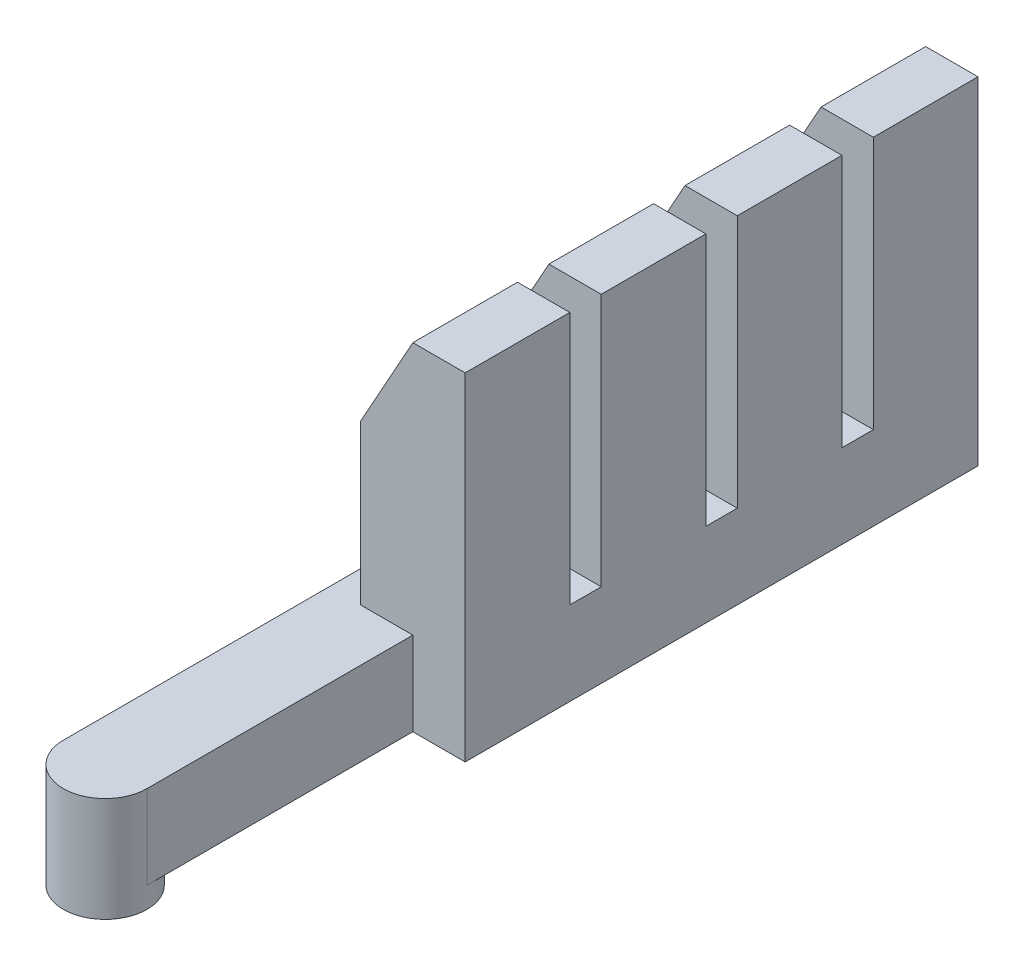
from build123d import *

# Parameters (mm, degrees)
SKETCH2_R               = 20
SKETCH2_R_2             = 10
BOSS_EXTRUDE1_DEPTH     = 80
SKETCH3_R               = 20
BOSS_EXTRUDE2_DEPTH     = 5
SKETCH4_W               = 30
SKETCH4_H               = 30
CUT_EXTRUDE1_DEPTH      = 50
SKETCH4_4_W             = 40
SKETCH4_4_H             = 40
SKETCH4_4_W_2           = 30
SKETCH4_4_H_2           = 30
BOSS_EXTRUDE3_DEPTH     = 127
SKETCH4_5_W             = 30
SKETCH4_5_H             = 30
CUT_EXTRUDE2_DEPTH      = 10
SKETCH5_R               = 10
CUT_EXTRUDE3_DEPTH      = 50
BOSS_EXTRUDE4_DEPTH     = 245
SKETCH7_W               = 25
SKETCH7_H               = 5
SKETCH7_W_2             = 55.000380238
BOSS_EXTRUDE5_DEPTH     = 35
SKETCH11_W              = 65
SKETCH11_H              = 5
BOSS_EXTRUDE9_DEPTH     = 245
SKETCH9_W               = 40
SKETCH9_H               = 40
CUT_EXTRUDE4_DEPTH      = 10
SKETCH9_4_W             = 50
SKETCH9_4_H             = 50
SKETCH9_4_W_2           = 40
SKETCH9_4_H_2           = 40
BOSS_EXTRUDE10_DEPTH    = 116
SKETCH13_W              = 50
SKETCH13_H              = 50
BOSS_EXTRUDE11_DEPTH    = 5
SKETCH14_W              = 40
SKETCH14_H              = 40
CUT_EXTRUDE5_DEPTH      = 5
CUT_EXTRUDE6_DEPTH      = 446.112345369
CUT_EXTRUDE7_DEPTH      = 431.168571609
CUT_EXTRUDE7_DEPTH_BACK = 431.168571609
SKETCH16_W              = 40
SKETCH16_H              = 35


with BuildPart() as part:
    # Sketch2 → Boss-Extrude1 (new body)
    with BuildSketch(Plane(origin=(0, 0, 0), x_dir=(1, 0, 0), z_dir=(0, 1, 0))):
        Circle(SKETCH2_R)
        Circle(SKETCH2_R_2, mode=Mode.SUBTRACT)
    extrude(amount=BOSS_EXTRUDE1_DEPTH)

    # Sketch3 → Boss-Extrude2 (add)
    with BuildSketch(Plane(origin=(0, 80, 0), x_dir=(1, 0, 0), z_dir=(0, 1, 0))):
        Circle(SKETCH3_R)
    extrude(amount=BOSS_EXTRUDE2_DEPTH)

    # Sketch4 → Cut-Extrude1 (cut)
    with BuildSketch(Plane.XY):
        with Locations((0, 65)):
            Rectangle(SKETCH4_W, SKETCH4_H)
    extrude(amount=-CUT_EXTRUDE1_DEPTH, mode=Mode.SUBTRACT)

    # Sketch4_4 → Boss-Extrude3 (add)
    with BuildSketch(Plane.XY):
        with Locations((0, 65)):
            Rectangle(SKETCH4_4_W, SKETCH4_4_H)
        with Locations((0, 65)):
            Rectangle(SKETCH4_4_W_2, SKETCH4_4_H_2, mode=Mode.SUBTRACT)
    extrude(amount=-BOSS_EXTRUDE3_DEPTH)

    # Sketch4_5 → Cut-Extrude2 (cut)
    with BuildSketch(Plane.XY):
        with Locations((0, 65)):
            Rectangle(SKETCH4_5_W, SKETCH4_5_H)
    extrude(amount=CUT_EXTRUDE2_DEPTH, mode=Mode.SUBTRACT)

    # Sketch5 → Cut-Extrude3 (cut)
    with BuildSketch(Plane.XZ):
        Circle(SKETCH5_R)
    extrude(amount=-CUT_EXTRUDE3_DEPTH, mode=Mode.SUBTRACT)

    # Sketch6 → Boss-Extrude4 (add)
    with BuildSketch(Plane(origin=(0, 0, -127), x_dir=(-1, 0, 0), z_dir=(0, 0, -1))):
        Polygon((0, 80), (0, 85), (20, 85), (20, 45), (-45, 45), (-45, 85), (-40, 85), (-40, 49.795485049), (15, 50), (15, 80), align=None)
    extrude(amount=BOSS_EXTRUDE4_DEPTH)

    # Sketch7 → Boss-Extrude5 (add)
    with BuildSketch(Plane(origin=(0.185712712, 49.943532631, 0), x_dir=(0.9999930866228877, -0.0037184279514581777, 0), z_dir=(0.0037184279514581777, 0.9999930866228877, 0))):
        with Locations((27.314562541, 129.5)):
            Rectangle(SKETCH7_W, SKETCH7_H)
        with Locations((12.314372422, 369.5)):
            Rectangle(SKETCH7_W_2, SKETCH7_H)
    extrude(amount=BOSS_EXTRUDE5_DEPTH)

    # Sketch11 → Boss-Extrude9 (add)
    with BuildSketch(Plane(origin=(0, 0, -372), x_dir=(-1, 0, 0), z_dir=(0, 0, -1))):
        with Locations((-12.5, 82.5)):
            Rectangle(SKETCH11_W, SKETCH11_H)
    extrude(amount=-BOSS_EXTRUDE9_DEPTH)

    # Sketch9 → Cut-Extrude4 (cut)
    with BuildSketch(Plane(origin=(0, 85, 0), x_dir=(1, 0, 0), z_dir=(0, 1, 0))):
        with Locations((20, 152)):
            Rectangle(SKETCH9_W, SKETCH9_H)
        with Locations((20, 217)):
            Rectangle(SKETCH9_W, SKETCH9_H)
        with Locations((20, 282)):
            Rectangle(SKETCH9_W, SKETCH9_H)
        with Locations((20, 347)):
            Rectangle(SKETCH9_W, SKETCH9_H)
    extrude(amount=-CUT_EXTRUDE4_DEPTH, mode=Mode.SUBTRACT)

    # Sketch9_4 → Boss-Extrude10 (add)
    # profile 1 of 4: a face of its own
    with BuildSketch(Plane(origin=(0, 85, 0), x_dir=(1, 0, 0), z_dir=(0, 1, 0))):
        with Locations((20, 152)):
            Rectangle(SKETCH9_4_W, SKETCH9_4_H)
        with Locations((20, 152)):
            Rectangle(SKETCH9_4_W_2, SKETCH9_4_H_2, mode=Mode.SUBTRACT)
    # profile 2 of 4: a face of its own
    with BuildSketch(Plane(origin=(0, 85, 0), x_dir=(1, 0, 0), z_dir=(0, 1, 0))):
        with Locations((20, 217)):
            Rectangle(SKETCH9_4_W, SKETCH9_4_H)
        with Locations((20, 217)):
            Rectangle(SKETCH9_4_W_2, SKETCH9_4_H_2, mode=Mode.SUBTRACT)
    # profile 3 of 4: a face of its own
    with BuildSketch(Plane(origin=(0, 85, 0), x_dir=(1, 0, 0), z_dir=(0, 1, 0))):
        with Locations((20, 282)):
            Rectangle(SKETCH9_4_W, SKETCH9_4_H)
        with Locations((20, 282)):
            Rectangle(SKETCH9_4_W_2, SKETCH9_4_H_2, mode=Mode.SUBTRACT)
    # profile 4 of 4: a face of its own
    with BuildSketch(Plane(origin=(0, 85, 0), x_dir=(1, 0, 0), z_dir=(0, 1, 0))):
        with Locations((20, 347)):
            Rectangle(SKETCH9_4_W, SKETCH9_4_H)
        with Locations((20, 347)):
            Rectangle(SKETCH9_4_W_2, SKETCH9_4_H_2, mode=Mode.SUBTRACT)
    extrude(amount=BOSS_EXTRUDE10_DEPTH)

    # Sketch13 → Boss-Extrude11 (add)
    with BuildSketch(Plane(origin=(0, 201, 0), x_dir=(1, 0, 0), z_dir=(0, 1, 0))):
        with Locations((20, 152)):
            Rectangle(SKETCH13_W, SKETCH13_H)
        with Locations((20, 217)):
            Rectangle(SKETCH13_W, SKETCH13_H)
        with Locations((20, 282)):
            Rectangle(SKETCH13_W, SKETCH13_H)
        with Locations((20, 347)):
            Rectangle(SKETCH13_W, SKETCH13_H)
    extrude(amount=BOSS_EXTRUDE11_DEPTH)

    # Sketch14 → Cut-Extrude5 (cut)
    with BuildSketch(Plane.ZY.offset(5)):
        with Locations((-347, 181)):
            Rectangle(SKETCH14_W, SKETCH14_H)
        with Locations((-282, 181)):
            Rectangle(SKETCH14_W, SKETCH14_H)
        with Locations((-217, 181)):
            Rectangle(SKETCH14_W, SKETCH14_H)
        with Locations((-152, 181)):
            Rectangle(SKETCH14_W, SKETCH14_H)
    extrude(amount=-CUT_EXTRUDE5_DEPTH, mode=Mode.SUBTRACT)

    # Sketch15 → Cut-Extrude6 (cut, through all)
    with BuildSketch(Plane(origin=(0, 0, -372), x_dir=(-1, 0, 0), z_dir=(0, 0, -1))):
        Polygon((5, 206), (-20, 206), (5, 161), align=None)
    extrude(amount=-CUT_EXTRUDE6_DEPTH, mode=Mode.SUBTRACT)

    # Sketch16 → Cut-Extrude7 (cut, two sides: drawn at the far end of the back side and taken through both)
    with BuildSketch(Plane.ZY.offset(20).offset(-CUT_EXTRUDE7_DEPTH_BACK)):
        with Locations((0, 17.5)):
            Rectangle(SKETCH16_W, SKETCH16_H)
    extrude(amount=CUT_EXTRUDE7_DEPTH + CUT_EXTRUDE7_DEPTH_BACK, mode=Mode.SUBTRACT)


solid = part.part
